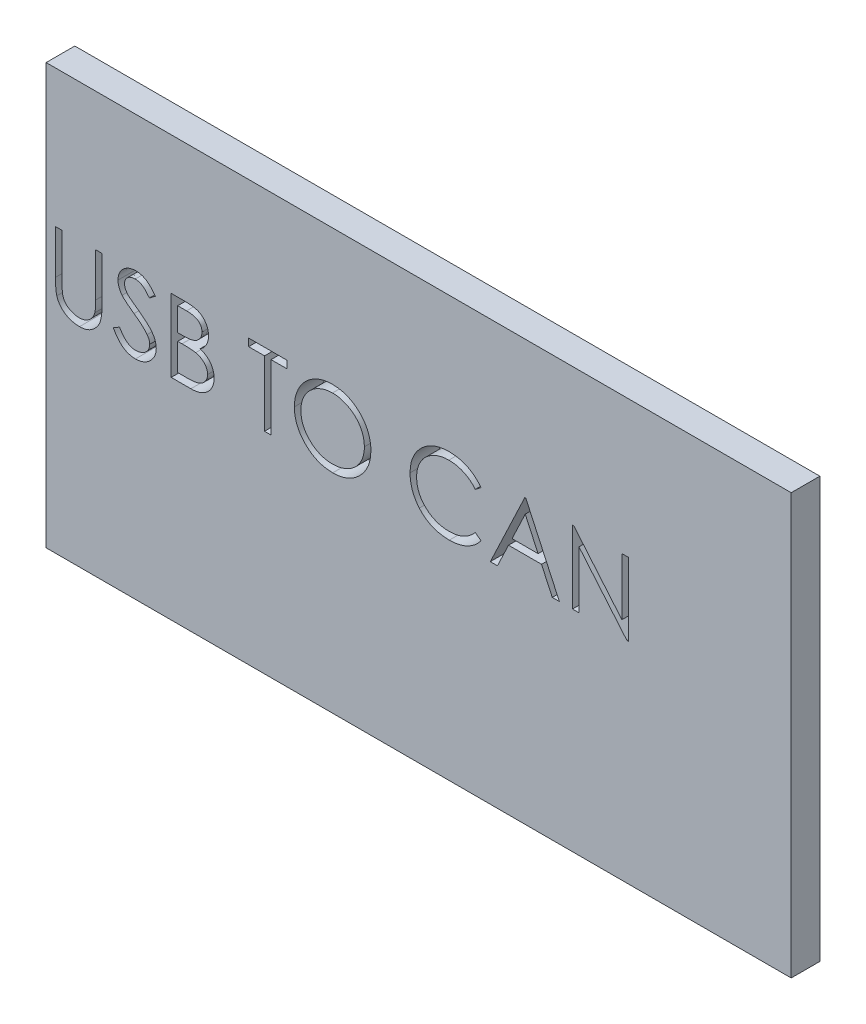
from build123d import *

# Parameters (mm, degrees)
SKETCH1_W               = 78
SKETCH1_H               = 44
BOSS_EXTRUDE1_DEPTH     = 3
CUT_EXTRUDE1_DEPTH      = 1
CUT_EXTRUDE1_DEPTH_BACK = 4


with BuildPart() as part:
    # Sketch1 → Boss-Extrude1 (new body)
    with BuildSketch(Plane.XY):
        Rectangle(SKETCH1_W, SKETCH1_H)
    extrude(amount=BOSS_EXTRUDE1_DEPTH)

    # Sketch2 → Cut-Extrude1 (cut, two sides)
    with BuildSketch(Plane.XY.offset(3)) as cut_extrude1_sk:
        with BuildLine():
            Line((-38.023076923, 7.62), (-37.339230769, 7.62))
            Line((-37.339230769, 7.62), (-37.339230769, 3.054411058))
            add(Edge.make_bspline(
                [(-37.339230769, 3.054411058), (-37.339332538, 2.989791856), (-37.33952566, 2.867165785), (-37.338235673, 2.692627942), (-37.334622991, 2.537457617), (-37.332345352, 2.401056683), (-37.327278415, 2.284051044), (-37.323146095, 2.185806796), (-37.317832655, 2.106789133), (-37.311446839, 2.060675231), (-37.308701923, 2.040853365)],
                knots=[0, 0, 0, 0, 0.000193858, 0.000367879, 0.000523606, 0.000659494, 0.000777119, 0.000874919, 0.000954528, 0.001014547, 0.001014547, 0.001014547, 0.001014547], degree=3))
            add(Edge.make_bspline(
                [(-37.308701923, 2.040853365), (-37.297429856, 1.969341269), (-37.275520861, 1.830346527), (-37.219685033, 1.632426211), (-37.141705217, 1.454049722), (-37.049300649, 1.289650854), (-36.927527364, 1.143805447), (-36.781651096, 1.009450363), (-36.604915497, 0.891946034), (-36.408405264, 0.784502267), (-36.196601404, 0.698145716), (-35.980168876, 0.632845877), (-35.762361018, 0.593050101), (-35.616544339, 0.588442093), (-35.544134615, 0.586153846)],
                knots=[0, 0, 0, 0, 0.000217082, 0.000421933, 0.000614749, 0.000800109, 0.000985589, 0.001182222, 0.00139307, 0.001620515, 0.001853241, 0.002077815, 0.002297904, 0.002515002, 0.002515002, 0.002515002, 0.002515002], degree=3))
            add(Edge.make_bspline(
                [(-35.544134615, 0.586153846), (-35.481969043, 0.588491772), (-35.357996952, 0.593154119), (-35.173796665, 0.622026149), (-34.994399857, 0.674061095), (-34.818920663, 0.741203655), (-34.654435377, 0.829916982), (-34.500852226, 0.932396924), (-34.363770746, 1.052598888), (-34.238676477, 1.185623067), (-34.129743273, 1.33571486), (-34.035318102, 1.49960612), (-33.957973078, 1.67976327), (-33.919778318, 1.806373755), (-33.90015625, 1.871418269)],
                knots=[0, 0, 0, 0, 0.000186532, 0.000371987, 0.000557549, 0.000746051, 0.000934521, 0.001116993, 0.001298788, 0.001480235, 0.001663726, 0.001853816, 0.002046631, 0.002250341, 0.002250341, 0.002250341, 0.002250341], degree=3))
            add(Edge.make_bspline(
                [(-33.90015625, 1.871418269), (-33.893624549, 1.89830288), (-33.879069286, 1.958212626), (-33.865468576, 2.059496122), (-33.851302941, 2.178998108), (-33.841474077, 2.317577198), (-33.831891992, 2.47476903), (-33.826159416, 2.651392482), (-33.823509761, 2.846806208), (-33.822720155, 2.983176257), (-33.822307692, 3.054411058)],
                knots=[0, 0, 0, 0, 8.2949e-05, 0.000184844, 0.000306213, 0.000444008, 0.000601498, 0.000778671, 0.000974079, 0.001187786, 0.001187786, 0.001187786, 0.001187786], degree=3))
            Line((-33.822307692, 3.054411058), (-33.822307692, 7.62))
            Line((-33.822307692, 7.62), (-33.138461538, 7.62))
            Line((-33.138461538, 7.62), (-33.138461538, 3.017776442))
            add(Edge.make_bspline(
                [(-33.138461538, 3.017776442), (-33.139014795, 2.934830829), (-33.140094508, 2.772957421), (-33.149457478, 2.535754748), (-33.164386146, 2.310740543), (-33.185478497, 2.097884559), (-33.213426487, 1.897948475), (-33.244505682, 1.709179808), (-33.284085122, 1.532933578), (-33.33031327, 1.367835572), (-33.383160252, 1.210677397), (-33.451612123, 1.061524356), (-33.52873632, 0.915842149), (-33.620208222, 0.775834209), (-33.722994146, 0.640880628), (-33.839366091, 0.511799841), (-33.965475264, 0.386529118), (-34.103418077, 0.268281814), (-34.250920649, 0.159841209), (-34.407544214, 0.064487204), (-34.572085638, -0.0161185), (-34.74411721, -0.082468941), (-34.923712343, -0.132357297), (-35.110875566, -0.169532351), (-35.306032896, -0.190655638), (-35.438761662, -0.193794926), (-35.505973558, -0.195384615)],
                knots=[0, 0, 0, 0, 0.000248829, 0.000485605, 0.000712033, 0.000925282, 0.001127125, 0.001317594, 0.001499055, 0.001668682, 0.001831847, 0.001995824, 0.002160411, 0.002325958, 0.002496927, 0.002668819, 0.002846917, 0.003029867, 0.003213358, 0.003395561, 0.003579198, 0.003762327, 0.003947888, 0.004137684, 0.004334233, 0.004535868, 0.004535868, 0.004535868, 0.004535868], degree=3))
            add(Edge.make_bspline(
                [(-35.505973558, -0.195384615), (-35.579276004, -0.193676069), (-35.723095141, -0.190323908), (-35.935014019, -0.171115521), (-36.138172355, -0.134934902), (-36.334715836, -0.088866682), (-36.521968621, -0.025329517), (-36.702439491, 0.048906972), (-36.873037534, 0.140079751), (-37.036530357, 0.241520223), (-37.188548826, 0.35565615), (-37.32809803, 0.480058471), (-37.455408354, 0.612734379), (-37.568333915, 0.755120318), (-37.66874567, 0.906108891), (-37.75524402, 1.066127236), (-37.829513426, 1.235113399), (-37.867845438, 1.352577224), (-37.887223558, 1.411959135)],
                knots=[0, 0, 0, 0, 0.00021994, 0.000431522, 0.000637552, 0.000838585, 0.001036493, 0.001230117, 0.001423349, 0.001616056, 0.001806861, 0.001992824, 0.002176366, 0.002357782, 0.002537286, 0.002719656, 0.002902855, 0.003090154, 0.003090154, 0.003090154, 0.003090154], degree=3))
            add(Edge.make_bspline(
                [(-37.887223558, 1.411959135), (-37.898494971, 1.452524911), (-37.922942916, 1.540512983), (-37.949123707, 1.686134424), (-37.971132622, 1.853806902), (-37.99182758, 2.043541894), (-38.004039083, 2.255486461), (-38.01474505, 2.489548729), (-38.023152345, 2.74601172), (-38.023102767, 2.924656122), (-38.023076923, 3.017776442)],
                knots=[0, 0, 0, 0, 0.000126253, 0.000273845, 0.000443307, 0.000633623, 0.000846243, 0.001080033, 0.001336589, 0.001615932, 0.001615932, 0.001615932, 0.001615932], degree=3))
            Line((-38.023076923, 3.017776442), (-38.023076923, 7.62))
        make_face()
        with BuildLine():
            Line((-31.966153846, 1.469963942), (-31.321995192, 1.856153846))
            add(Edge.make_bspline(
                [(-31.321995192, 1.856153846), (-31.262084059, 1.755865099), (-31.147296639, 1.563715731), (-30.955813965, 1.30407394), (-30.757404599, 1.083394045), (-30.55059925, 0.902959831), (-30.336660242, 0.760903683), (-30.11419096, 0.660314824), (-29.883941098, 0.597578329), (-29.727243806, 0.589958141), (-29.649014423, 0.586153846)],
                knots=[0, 0, 0, 0, 0.000350304, 0.00067117, 0.000966168, 0.001238859, 0.00149246, 0.001733624, 0.001968725, 0.002203113, 0.002203113, 0.002203113, 0.002203113], degree=3))
            add(Edge.make_bspline(
                [(-29.649014423, 0.586153846), (-29.582204744, 0.58801459), (-29.449754398, 0.59170352), (-29.2547646, 0.627149152), (-29.065392791, 0.68160413), (-28.885541985, 0.759591415), (-28.717693819, 0.853945489), (-28.570504385, 0.967910596), (-28.443258847, 1.095504678), (-28.339171575, 1.237852058), (-28.259313898, 1.390942535), (-28.197935738, 1.548079892), (-28.163874177, 1.711732604), (-28.158743188, 1.821918812), (-28.156153846, 1.877524038)],
                knots=[0, 0, 0, 0, 0.000200249, 0.000396995, 0.000592623, 0.000790249, 0.000983746, 0.001168767, 0.001346865, 0.001522724, 0.001695482, 0.001863598, 0.002027355, 0.002194185, 0.002194185, 0.002194185, 0.002194185], degree=3))
            add(Edge.make_bspline(
                [(-28.156153846, 1.877524038), (-28.159363631, 1.940967831), (-28.165888655, 2.069939791), (-28.221038906, 2.260221321), (-28.307796409, 2.448528002), (-28.387833936, 2.5650079), (-28.429387019, 2.625480769)],
                knots=[0, 0, 0, 0, 0.000190022, 0.000386287, 0.000589808, 0.000809558, 0.000809558, 0.000809558, 0.000809558], degree=3))
            add(Edge.make_bspline(
                [(-28.429387019, 2.625480769), (-28.463504185, 2.669125568), (-28.535128907, 2.760752364), (-28.658262691, 2.897139991), (-28.802751203, 3.03782352), (-28.9636498, 3.188174953), (-29.146819553, 3.341201527), (-29.346523456, 3.504200464), (-29.5678602, 3.67097304), (-29.72308939, 3.782818454), (-29.803185096, 3.840528846)],
                knots=[0, 0, 0, 0, 0.000166158, 0.000348828, 0.000550671, 0.000771029, 0.001009281, 0.001266508, 0.001544325, 0.00184049, 0.00184049, 0.00184049, 0.00184049], degree=3))
            add(Edge.make_bspline(
                [(-29.803185096, 3.840528846), (-29.883356196, 3.897632228), (-30.036637235, 4.006809547), (-30.250995634, 4.168841845), (-30.442681008, 4.31698307), (-30.610841381, 4.452627805), (-30.755402789, 4.575794447), (-30.877504387, 4.685300246), (-30.97403576, 4.784106741), (-31.027714481, 4.848204748), (-31.051814904, 4.876983173)],
                knots=[0, 0, 0, 0, 0.000295271, 0.000564536, 0.000806051, 0.001022036, 0.001212603, 0.001375761, 0.001513936, 0.001626521, 0.001626521, 0.001626521, 0.001626521], degree=3))
            add(Edge.make_bspline(
                [(-31.051814904, 4.876983173), (-31.085500845, 4.921834573), (-31.15174877, 5.010040871), (-31.239195902, 5.147908133), (-31.313521736, 5.289037642), (-31.371787156, 5.433808639), (-31.420851724, 5.580188684), (-31.453852705, 5.730087682), (-31.474516832, 5.882833017), (-31.476632985, 5.985623552), (-31.477692308, 6.037079327)],
                knots=[0, 0, 0, 0, 0.000168228, 0.000330842, 0.000489239, 0.000645995, 0.000798533, 0.000951847, 0.001105776, 0.001260067, 0.001260067, 0.001260067, 0.001260067], degree=3))
            add(Edge.make_bspline(
                [(-31.477692308, 6.037079327), (-31.474850681, 6.117698436), (-31.469228166, 6.277213478), (-31.42167824, 6.510234886), (-31.346625826, 6.732709314), (-31.241480956, 6.942434212), (-31.105937804, 7.133948719), (-30.949083426, 7.309455796), (-30.762259562, 7.456997681), (-30.55727585, 7.585910791), (-30.332907406, 7.686812491), (-30.097795782, 7.762927539), (-29.8515673, 7.806055123), (-29.684791332, 7.812244229), (-29.600168269, 7.815384615)],
                knots=[0, 0, 0, 0, 0.00024166, 0.000478156, 0.00071034, 0.000944489, 0.001179085, 0.001412476, 0.001648008, 0.001890713, 0.002137308, 0.002383992, 0.002630431, 0.00288428, 0.00288428, 0.00288428, 0.00288428], degree=3))
            add(Edge.make_bspline(
                [(-29.600168269, 7.815384615), (-29.510373971, 7.812287517), (-29.331801771, 7.806128378), (-29.069131193, 7.752576038), (-28.816232719, 7.663964861), (-28.612793382, 7.563405555), (-28.453572913, 7.462970872), (-28.332147707, 7.371487712), (-28.209101142, 7.26616819), (-28.083440691, 7.146731774), (-27.957295599, 7.012082562), (-27.828793111, 6.863142719), (-27.697632732, 6.700822446), (-27.613255688, 6.584945104), (-27.57, 6.525540865)],
                knots=[0, 0, 0, 0, 0.000269178, 0.000535309, 0.000800335, 0.001071346, 0.001214058, 0.001364566, 0.001526987, 0.001699738, 0.001884387, 0.002080254, 0.0022898, 0.002510221, 0.002510221, 0.002510221, 0.002510221], degree=3))
            Line((-27.57, 6.525540865), (-28.188209135, 6.056923077))
            add(Edge.make_bspline(
                [(-28.188209135, 6.056923077), (-28.225538279, 6.105013312), (-28.297425483, 6.197623859), (-28.406564538, 6.327319124), (-28.509431594, 6.445791573), (-28.610778464, 6.548694509), (-28.705252599, 6.641663154), (-28.796947417, 6.721258967), (-28.884543347, 6.788261835), (-28.994961307, 6.859766957), (-29.133683882, 6.930647116), (-29.307821644, 6.990625395), (-29.489800906, 7.02666813), (-29.613744846, 7.03143365), (-29.676490385, 7.033846154)],
                knots=[0, 0, 0, 0, 0.000182613, 0.000351669, 0.000508477, 0.000653127, 0.000784826, 0.000906023, 0.001017149, 0.001115377, 0.001300379, 0.001482851, 0.001666361, 0.00185451, 0.00185451, 0.00185451, 0.00185451], degree=3))
            add(Edge.make_bspline(
                [(-29.676490385, 7.033846154), (-29.755208299, 7.03120811), (-29.907008382, 7.026120891), (-30.122524267, 6.970560237), (-30.31649447, 6.883078587), (-30.48316034, 6.760472835), (-30.621924844, 6.615211702), (-30.722303015, 6.448053166), (-30.782719087, 6.263469764), (-30.790091502, 6.134709929), (-30.793846154, 6.069134615)],
                knots=[0, 0, 0, 0, 0.000235671, 0.000454469, 0.000662788, 0.000870407, 0.001071272, 0.001261588, 0.001450818, 0.001647207, 0.001647207, 0.001647207, 0.001647207], degree=3))
            add(Edge.make_bspline(
                [(-30.793846154, 6.069134615), (-30.792990261, 6.028309968), (-30.791277076, 5.946593916), (-30.767383373, 5.825868249), (-30.73668712, 5.705447562), (-30.688044019, 5.585873253), (-30.620889386, 5.465054105), (-30.532703832, 5.340909637), (-30.421640564, 5.212345631), (-30.336564326, 5.128727291), (-30.291646635, 5.084579327)],
                knots=[0, 0, 0, 0, 0.000122268, 0.000244736, 0.000368038, 0.000494742, 0.000630698, 0.000781885, 0.000950762, 0.001139653, 0.001139653, 0.001139653, 0.001139653], degree=3))
            add(Edge.make_bspline(
                [(-30.291646635, 5.084579327), (-30.274966732, 5.069694145), (-30.235339103, 5.03433036), (-30.162892659, 4.976435166), (-30.067222909, 4.905018845), (-29.95082806, 4.816654459), (-29.811561975, 4.71415139), (-29.649409342, 4.598820268), (-29.466177662, 4.466917069), (-29.336154519, 4.374698652), (-29.267403846, 4.3259375)],
                knots=[0, 0, 0, 0, 6.7059e-05, 0.000159318, 0.000278076, 0.000425226, 0.00059772, 0.000796814, 0.00102217, 0.00127503, 0.00127503, 0.00127503, 0.00127503], degree=3))
            add(Edge.make_bspline(
                [(-29.267403846, 4.3259375), (-29.184703086, 4.265758311), (-29.024564527, 4.149229654), (-28.796710024, 3.97415323), (-28.590112648, 3.802925803), (-28.404047045, 3.636640841), (-28.236675033, 3.476559678), (-28.089853481, 3.320756412), (-27.962086371, 3.17034725), (-27.824536187, 2.9775121), (-27.683984591, 2.740680139), (-27.563280509, 2.450514374), (-27.487171193, 2.159220671), (-27.477218351, 1.963437101), (-27.472307692, 1.866838942)],
                knots=[0, 0, 0, 0, 0.00030683, 0.000594134, 0.000861889, 0.001111615, 0.001342638, 0.001556449, 0.001753649, 0.001934112, 0.002266596, 0.002577286, 0.002874571, 0.0031641, 0.0031641, 0.0031641, 0.0031641], degree=3))
            add(Edge.make_bspline(
                [(-27.472307692, 1.866838942), (-27.473738376, 1.798523759), (-27.47657196, 1.663220027), (-27.509144007, 1.464544688), (-27.556866249, 1.271582623), (-27.628793027, 1.086719001), (-27.716582303, 0.906571832), (-27.827978534, 0.735866632), (-27.957099836, 0.570825273), (-28.105219062, 0.415848643), (-28.267298426, 0.273580639), (-28.43860407, 0.147025368), (-28.619416378, 0.041502904), (-28.808754474, -0.044604929), (-29.006661847, -0.111951616), (-29.213071936, -0.160747634), (-29.428324986, -0.190695782), (-29.574630035, -0.193804222), (-29.649014423, -0.195384615)],
                knots=[0, 0, 0, 0, 0.000204748, 0.00040552, 0.000602479, 0.000800075, 0.000999409, 0.001202649, 0.001410296, 0.001627314, 0.001844718, 0.002056602, 0.002265256, 0.002471552, 0.002679602, 0.002891382, 0.003107043, 0.003330092, 0.003330092, 0.003330092, 0.003330092], degree=3))
            add(Edge.make_bspline(
                [(-29.649014423, -0.195384615), (-29.706567941, -0.1942717), (-29.82095015, -0.192059885), (-29.990134794, -0.172506355), (-30.155901556, -0.144841175), (-30.316170365, -0.100919343), (-30.473006101, -0.047629467), (-30.625726652, 0.017985989), (-30.774406032, 0.096618296), (-30.919877455, 0.186523464), (-31.061770944, 0.291152039), (-31.198755614, 0.413014337), (-31.335326012, 0.548749408), (-31.467451143, 0.702043263), (-31.597803532, 0.870419318), (-31.723813098, 1.055452911), (-31.848088152, 1.256136178), (-31.926063542, 1.397356737), (-31.966153846, 1.469963942)],
                knots=[0, 0, 0, 0, 0.000172596, 0.000343018, 0.000510406, 0.000676283, 0.000840891, 0.001007049, 0.001174332, 0.001345035, 0.001519664, 0.001702462, 0.001894587, 0.002096914, 0.002309112, 0.002533088, 0.00276819, 0.003016977, 0.003016977, 0.003016977, 0.003016977], degree=3))
        make_face()
        with BuildLine():
            Line((-25.909230769, 7.62), (-24.422475962, 7.62))
            add(Edge.make_bspline(
                [(-24.422475962, 7.62), (-24.349697389, 7.619617366), (-24.208634403, 7.618875727), (-24.003505218, 7.607373596), (-23.81137495, 7.591690177), (-23.63218788, 7.566805233), (-23.466026808, 7.536778564), (-23.31239098, 7.500416324), (-23.171768948, 7.456815525), (-23.003883505, 7.387481621), (-22.812467666, 7.284452323), (-22.605207166, 7.132207847), (-22.427978507, 6.945991456), (-22.275172868, 6.735934932), (-22.153685859, 6.504862195), (-22.065796132, 6.258280761), (-22.010152986, 5.99937114), (-22.004430509, 5.821622278), (-22.001538462, 5.731790865)],
                knots=[0, 0, 0, 0, 0.000218303, 0.000423125, 0.000616188, 0.000796444, 0.000965604, 0.001122583, 0.001269827, 0.00140674, 0.001666957, 0.001920042, 0.002174807, 0.002434948, 0.002697141, 0.00295497, 0.003218413, 0.003487591, 0.003487591, 0.003487591, 0.003487591], degree=3))
            add(Edge.make_bspline(
                [(-22.001538462, 5.731790865), (-22.003918554, 5.64763873), (-22.008595661, 5.482271848), (-22.053320183, 5.240404101), (-22.123338552, 5.01016859), (-22.220668266, 4.792405569), (-22.347164612, 4.592035245), (-22.497079009, 4.407441254), (-22.677949076, 4.246439239), (-22.813461501, 4.156429834), (-22.882295673, 4.110709135)],
                knots=[0, 0, 0, 0, 0.000252237, 0.00049567, 0.000735161, 0.000972914, 0.001208822, 0.001444137, 0.001684104, 0.00193183, 0.00193183, 0.00193183, 0.00193183], degree=3))
            add(Edge.make_bspline(
                [(-22.882295673, 4.110709135), (-22.795731542, 4.077475051), (-22.630112916, 4.013890017), (-22.402196512, 3.901472235), (-22.205829449, 3.779199298), (-22.039501949, 3.645671098), (-21.89725254, 3.501742773), (-21.773040136, 3.345303924), (-21.66705383, 3.174313829), (-21.576238836, 2.990555275), (-21.505375544, 2.795904621), (-21.452305718, 2.592187674), (-21.421896586, 2.380134928), (-21.417569207, 2.235822188), (-21.415384615, 2.16296875)],
                knots=[0, 0, 0, 0, 0.000278068, 0.000532013, 0.000761127, 0.000970673, 0.001170357, 0.001367031, 0.001568637, 0.001772753, 0.001980893, 0.00218896, 0.00240332, 0.002621863, 0.002621863, 0.002621863, 0.002621863], degree=3))
            add(Edge.make_bspline(
                [(-21.415384615, 2.16296875), (-21.417511349, 2.088582588), (-21.421695756, 1.942225732), (-21.45256758, 1.727221696), (-21.504838836, 1.521753955), (-21.576839446, 1.324493528), (-21.670809971, 1.135822036), (-21.785170854, 0.95552573), (-21.921528715, 0.78541613), (-22.07406559, 0.623602985), (-22.246630604, 0.478109345), (-22.432810619, 0.348535149), (-22.634950321, 0.24197258), (-22.849729805, 0.152457127), (-23.079558402, 0.084079169), (-23.323404078, 0.036241737), (-23.58105653, 0.004009056), (-23.757861759, 0.001359027), (-23.848533654, 0)],
                knots=[0, 0, 0, 0, 0.000223117, 0.000438988, 0.000650013, 0.000858153, 0.001067726, 0.00128115, 0.001497372, 0.001720864, 0.001947195, 0.002173294, 0.002400016, 0.002631331, 0.002870379, 0.003117949, 0.003376203, 0.003648064, 0.003648064, 0.003648064, 0.003648064], degree=3))
            Line((-23.848533654, 0), (-25.909230769, 0))
            Line((-25.909230769, 0), (-25.909230769, 7.62))
        make_face()
        with BuildLine():
            Line((-25.225384615, 6.838461538), (-25.225384615, 4.396153846))
            Line((-25.225384615, 4.396153846), (-24.765925481, 4.396153846))
            add(Edge.make_bspline(
                [(-24.765925481, 4.396153846), (-24.698763246, 4.397024536), (-24.568992122, 4.398706885), (-24.381061376, 4.403526028), (-24.206617765, 4.417020054), (-24.045962403, 4.430510202), (-23.899348282, 4.452444018), (-23.767100218, 4.478552583), (-23.647142701, 4.506165079), (-23.508808033, 4.553124934), (-23.351894928, 4.622527186), (-23.184618285, 4.730234441), (-23.037150668, 4.858521176), (-22.912624219, 5.006547213), (-22.81070896, 5.169541594), (-22.739921958, 5.34490366), (-22.69192187, 5.528262919), (-22.687586022, 5.654141515), (-22.685384615, 5.718052885)],
                knots=[0, 0, 0, 0, 0.000201514, 0.000389365, 0.000563808, 0.000726329, 0.000872907, 0.001008219, 0.001130763, 0.001241785, 0.00144606, 0.001643798, 0.00183636, 0.002030242, 0.002222143, 0.002410366, 0.002595846, 0.002787146, 0.002787146, 0.002787146, 0.002787146], degree=3))
            add(Edge.make_bspline(
                [(-22.685384615, 5.718052885), (-22.686530185, 5.760345564), (-22.688777344, 5.843307274), (-22.707181392, 5.964246153), (-22.738461654, 6.077988266), (-22.778639286, 6.186092358), (-22.834784946, 6.285178157), (-22.900890543, 6.378671629), (-22.980760532, 6.46338887), (-23.071672167, 6.542570463), (-23.176193797, 6.612771407), (-23.294263067, 6.674255583), (-23.427477381, 6.723765502), (-23.573591654, 6.767125811), (-23.734854993, 6.797580325), (-23.909406449, 6.822951415), (-24.098675752, 6.835867842), (-24.229620232, 6.837577689), (-24.297307692, 6.838461538)],
                knots=[0, 0, 0, 0, 0.000126842, 0.000248814, 0.000365823, 0.000480347, 0.000593767, 0.000706445, 0.000823096, 0.000942139, 0.001067456, 0.001199905, 0.001340512, 0.001493156, 0.001656606, 0.001832326, 0.002022103, 0.002225172, 0.002225172, 0.002225172, 0.002225172], degree=3))
            Line((-24.297307692, 6.838461538), (-25.225384615, 6.838461538))
        make_face(mode=Mode.SUBTRACT)
        with BuildLine():
            Line((-25.225384615, 3.614615385), (-25.225384615, 0.781538462))
            Line((-25.225384615, 0.781538462), (-24.251514423, 0.781538462))
            add(Edge.make_bspline(
                [(-24.251514423, 0.781538462), (-24.181804647, 0.782373934), (-24.047448244, 0.783984198), (-23.853462138, 0.789241029), (-23.673666923, 0.801198497), (-23.508883039, 0.820021747), (-23.357331139, 0.840439971), (-23.220829283, 0.867896531), (-23.098270959, 0.899353982), (-22.956159466, 0.947978666), (-22.796131828, 1.02351784), (-22.623678478, 1.137413384), (-22.47035054, 1.273100128), (-22.340145947, 1.430139433), (-22.233437669, 1.600895636), (-22.15581065, 1.781914941), (-22.107933413, 1.970206289), (-22.10213749, 2.098585246), (-22.099230769, 2.16296875)],
                knots=[0, 0, 0, 0, 0.000209145, 0.000403099, 0.00058211, 0.000749497, 0.000900607, 0.001040708, 0.001166961, 0.001279917, 0.001490909, 0.001695816, 0.001898005, 0.002102827, 0.002305729, 0.002499948, 0.002691721, 0.002884658, 0.002884658, 0.002884658, 0.002884658], degree=3))
            add(Edge.make_bspline(
                [(-22.099230769, 2.16296875), (-22.099831888, 2.203231394), (-22.101024429, 2.283107243), (-22.119008968, 2.400489683), (-22.145164878, 2.51419287), (-22.178979029, 2.624525551), (-22.22822484, 2.729492959), (-22.285715661, 2.831171103), (-22.353123055, 2.929694392), (-22.458157496, 3.054253641), (-22.610931931, 3.197764395), (-22.828007825, 3.338271757), (-23.074835514, 3.451587269), (-23.253856513, 3.499700986), (-23.346334135, 3.524555288)],
                knots=[0, 0, 0, 0, 0.000120676, 0.000239405, 0.000355304, 0.00047068, 0.000584755, 0.000702331, 0.000820883, 0.000942252, 0.001190655, 0.001446369, 0.001714819, 0.002001676, 0.002001676, 0.002001676, 0.002001676], degree=3))
            add(Edge.make_bspline(
                [(-23.346334135, 3.524555288), (-23.383408909, 3.5320775), (-23.463794667, 3.548387206), (-23.594875171, 3.565603406), (-23.744522977, 3.580941507), (-23.913083641, 3.592286942), (-24.100770427, 3.604014217), (-24.307984175, 3.608574942), (-24.533878672, 3.614016188), (-24.690616351, 3.614410543), (-24.77203125, 3.614615385)],
                knots=[0, 0, 0, 0, 0.000113461, 0.000246007, 0.000396375, 0.000564727, 0.000752783, 0.000960469, 0.001186429, 0.001430665, 0.001430665, 0.001430665, 0.001430665], degree=3))
            Line((-24.77203125, 3.614615385), (-25.225384615, 3.614615385))
        make_face(mode=Mode.SUBTRACT)
        Polygon((-17.800769231, 6.838461538), (-17.800769231, 7.62), (-13.795384615, 7.62), (-13.795384615, 6.838461538), (-15.456153846, 6.838461538), (-15.456153846, 0), (-16.14, 0), (-16.14, 6.838461538), align=None)
        with BuildLine():
            add(Edge.make_bspline(
                [(-9.057307692, 7.815384615), (-8.916211187, 7.81181088), (-8.639086011, 7.80479177), (-8.231797233, 7.751061836), (-7.842970197, 7.658107872), (-7.469437495, 7.534309036), (-7.115667072, 7.369163203), (-6.778996112, 7.169551537), (-6.460225661, 6.93338279), (-6.163652253, 6.662482587), (-5.892256264, 6.367733468), (-5.65314962, 6.053184418), (-5.452760398, 5.720737311), (-5.288199341, 5.37139116), (-5.159097797, 5.005936029), (-5.070011193, 4.622423601), (-5.013104706, 4.22333875), (-5.006451842, 3.951137404), (-5.003076923, 3.813052885)],
                knots=[0, 0, 0, 0, 0.000423221, 0.000831241, 0.001229628, 0.001621103, 0.002009702, 0.002398454, 0.002793504, 0.003197651, 0.0036017, 0.003993999, 0.004380915, 0.004763982, 0.005150679, 0.005541287, 0.00594346, 0.006357532, 0.006357532, 0.006357532, 0.006357532], degree=3))
            add(Edge.make_bspline(
                [(-5.003076923, 3.813052885), (-5.006451348, 3.67598553), (-5.013102729, 3.405809895), (-5.070075896, 3.009257596), (-5.159428016, 2.628060137), (-5.287000459, 2.262853887), (-5.450777072, 1.913253591), (-5.652500616, 1.580179137), (-5.890116623, 1.263521332), (-6.160532682, 0.966749187), (-6.455320093, 0.694611836), (-6.771507131, 0.457479884), (-7.101982873, 0.253429076), (-7.451000009, 0.090614334), (-7.813929804, -0.039517675), (-8.194020462, -0.128241973), (-8.589490959, -0.185472621), (-8.85917583, -0.192044362), (-8.99625, -0.195384615)],
                knots=[0, 0, 0, 0, 0.000411021, 0.000810171, 0.001199294, 0.001584045, 0.001968493, 0.00235541, 0.002750148, 0.003154295, 0.003558344, 0.003951861, 0.004338265, 0.004721332, 0.00510515, 0.005492788, 0.005890425, 0.006301447, 0.006301447, 0.006301447, 0.006301447], degree=3))
            add(Edge.make_bspline(
                [(-8.99625, -0.195384615), (-9.134333803, -0.192011379), (-9.406533736, -0.185361832), (-9.806120082, -0.128361173), (-10.189901913, -0.039226106), (-10.556781729, 0.088157295), (-10.906964118, 0.252786809), (-11.241133955, 0.453528914), (-11.557949927, 0.69172389), (-11.854785387, 0.962052261), (-12.126382213, 1.25634004), (-12.363166911, 1.571664904), (-12.563954157, 1.901840498), (-12.728030898, 2.247783108), (-12.85792895, 2.607820363), (-12.946549154, 2.984353905), (-13.003886284, 3.375237058), (-13.010493578, 3.641377311), (-13.013846154, 3.776418269)],
                knots=[0, 0, 0, 0, 0.000414071, 0.000816245, 0.001208338, 0.001594531, 0.00197898, 0.002367203, 0.002761941, 0.003166089, 0.003570138, 0.003961517, 0.004347128, 0.004727436, 0.005108377, 0.005493046, 0.005886149, 0.006291071, 0.006291071, 0.006291071, 0.006291071], degree=3))
            add(Edge.make_bspline(
                [(-13.013846154, 3.776418269), (-13.012682176, 3.867058537), (-13.010368904, 4.047195606), (-12.982519562, 4.314693747), (-12.942108087, 4.577889979), (-12.884191923, 4.836035872), (-12.808445494, 5.088499501), (-12.719069366, 5.337022019), (-12.60990776, 5.579084869), (-12.486505892, 5.815834768), (-12.348775898, 6.043581123), (-12.196646409, 6.258856101), (-12.035460836, 6.463466157), (-11.858756533, 6.652109062), (-11.672357301, 6.830272623), (-11.473239346, 6.995218881), (-11.26261766, 7.148435203), (-11.039585965, 7.286510345), (-10.809639892, 7.411389376), (-10.572599593, 7.518552377), (-10.331684429, 7.610528088), (-10.085766024, 7.685075256), (-9.835497417, 7.74392786), (-9.580332389, 7.784003299), (-9.320474221, 7.811923671), (-9.145407292, 7.814226004), (-9.057307692, 7.815384615)],
                knots=[0, 0, 0, 0, 0.000271814, 0.000540199, 0.000805962, 0.001070372, 0.001333106, 0.001596279, 0.001862082, 0.002129039, 0.002396846, 0.002659828, 0.002919436, 0.003177585, 0.003434554, 0.003692536, 0.003952677, 0.004215283, 0.004478911, 0.004737128, 0.004995111, 0.005251998, 0.00550748, 0.005765706, 0.006026495, 0.00629068, 0.00629068, 0.00629068, 0.00629068], degree=3))
        make_face()
        with BuildLine():
            add(Edge.make_bspline(
                [(-9.023725962, 7.033846154), (-9.096038964, 7.03296465), (-9.239973651, 7.031210069), (-9.453953127, 7.00809814), (-9.665118423, 6.97515821), (-9.873513148, 6.928172157), (-10.078265356, 6.864155333), (-10.281283581, 6.790478841), (-10.480716516, 6.700734639), (-10.675905772, 6.599339208), (-10.865132307, 6.487109843), (-11.043685674, 6.363074168), (-11.212028116, 6.230140972), (-11.369747457, 6.088000023), (-11.51638058, 5.935927462), (-11.654813559, 5.776228729), (-11.779497619, 5.604339184), (-11.893766218, 5.424919955), (-11.996021916, 5.238204741), (-12.08695106, 5.04615927), (-12.161330987, 4.847216992), (-12.221991361, 4.643536226), (-12.272282949, 4.435439556), (-12.304143092, 4.221348365), (-12.327508972, 4.002338436), (-12.329163264, 3.854332228), (-12.33, 3.779471154)],
                knots=[0, 0, 0, 0, 0.000216841, 0.000431609, 0.000644918, 0.000857839, 0.001071742, 0.001288099, 0.00150539, 0.001727277, 0.001947698, 0.002164915, 0.002378992, 0.002590822, 0.002801321, 0.003012418, 0.003224302, 0.003437726, 0.003650187, 0.00386256, 0.004074625, 0.004286625, 0.00449989, 0.004716215, 0.00493554, 0.00516001, 0.00516001, 0.00516001, 0.00516001], degree=3))
            add(Edge.make_bspline(
                [(-12.33, 3.779471154), (-12.327224443, 3.669389976), (-12.321764065, 3.452826244), (-12.273959298, 3.135468171), (-12.200324028, 2.830475959), (-12.091777419, 2.539518431), (-11.956031223, 2.260094592), (-11.788332679, 1.994683233), (-11.589648613, 1.743212621), (-11.363958307, 1.507438349), (-11.117238585, 1.292236913), (-10.855257042, 1.103340577), (-10.580820331, 0.943515976), (-10.293212787, 0.81331179), (-9.993969859, 0.710137561), (-9.681163305, 0.639426941), (-9.356876876, 0.592889521), (-9.135830135, 0.588420378), (-9.023725962, 0.586153846)],
                knots=[0, 0, 0, 0, 0.000330065, 0.000649339, 0.000960692, 0.001269773, 0.001579024, 0.001891143, 0.002209643, 0.002538934, 0.002868918, 0.00319045, 0.003506453, 0.003820003, 0.004136183, 0.004454247, 0.004780867, 0.005116965, 0.005116965, 0.005116965, 0.005116965], degree=3))
            add(Edge.make_bspline(
                [(-9.023725962, 0.586153846), (-8.948376132, 0.587189087), (-8.79893479, 0.589242281), (-8.576658253, 0.609922257), (-8.358386158, 0.643084213), (-8.144424657, 0.690830383), (-7.935016582, 0.750586873), (-7.729287896, 0.821578555), (-7.529429904, 0.910147347), (-7.332921343, 1.008005458), (-7.144824383, 1.119562601), (-6.965263367, 1.239388516), (-6.798764233, 1.372125913), (-6.641162884, 1.512154979), (-6.493927743, 1.662299128), (-6.358054469, 1.822363154), (-6.234000582, 1.993357384), (-6.119775374, 2.172504468), (-6.017877985, 2.359730595), (-5.92909606, 2.552472351), (-5.853775374, 2.750255132), (-5.792971029, 2.953364211), (-5.745323253, 3.16141383), (-5.712492113, 3.37468256), (-5.689526655, 3.592743757), (-5.687795658, 3.740231809), (-5.686923077, 3.814579327)],
                knots=[0, 0, 0, 0, 0.000225996, 0.000448218, 0.000669067, 0.000887945, 0.001105376, 0.001322137, 0.00154021, 0.001760705, 0.001980349, 0.002195842, 0.002407776, 0.002618585, 0.002827992, 0.003038098, 0.003247849, 0.003461273, 0.003675073, 0.003886803, 0.004097441, 0.004309441, 0.004522362, 0.004737178, 0.004956503, 0.005179447, 0.005179447, 0.005179447, 0.005179447], degree=3))
            add(Edge.make_bspline(
                [(-5.686923077, 3.814579327), (-5.687796357, 3.888418225), (-5.689528669, 4.03489128), (-5.712481143, 4.251431691), (-5.745357938, 4.463165825), (-5.792738463, 4.669262448), (-5.853807655, 4.869774094), (-5.929109214, 5.064512442), (-6.017904637, 5.254202969), (-6.119812829, 5.438376839), (-6.234364993, 5.61510584), (-6.359538174, 5.784057378), (-6.497493589, 5.942058603), (-6.644289678, 6.093010137), (-6.803593148, 6.233692514), (-6.974682382, 6.364152402), (-7.155480332, 6.487538216), (-7.346910485, 6.598845868), (-7.544473036, 6.701637997), (-7.747195424, 6.78970561), (-7.952781064, 6.864538624), (-8.16070716, 6.928365845), (-8.372723816, 6.974974185), (-8.587398437, 7.008127825), (-8.804434017, 7.031202025), (-8.950396684, 7.032961981), (-9.023725962, 7.033846154)],
                knots=[0, 0, 0, 0, 0.000221418, 0.000439224, 0.000652533, 0.000863966, 0.001073044, 0.001280831, 0.001489792, 0.001700916, 0.00191177, 0.002121198, 0.002331138, 0.002540545, 0.002752495, 0.002968043, 0.003185656, 0.003408704, 0.003631946, 0.003853428, 0.004071217, 0.004288042, 0.00450543, 0.004721754, 0.00493956, 0.005159453, 0.005159453, 0.005159453, 0.005159453], degree=3))
        make_face(mode=Mode.SUBTRACT)
        with BuildLine():
            Line((6.524615385, 6.221778846), (5.92625, 5.763846154))
            add(Edge.make_bspline(
                [(5.92625, 5.763846154), (5.88356518, 5.814717208), (5.798771025, 5.915773465), (5.662352989, 6.057678644), (5.520181984, 6.190626442), (5.372312354, 6.315250191), (5.2160825, 6.427191836), (5.05527699, 6.532284923), (4.887205817, 6.626484969), (4.65479204, 6.740704385), (4.350758725, 6.859894585), (3.968028247, 6.959832477), (3.56849837, 7.023451151), (3.29592531, 7.030341463), (3.157283654, 7.033846154)],
                knots=[0, 0, 0, 0, 0.000199176, 0.000395666, 0.000590059, 0.000782959, 0.000975315, 0.001166267, 0.00135901, 0.001552886, 0.00194293, 0.002336139, 0.002737684, 0.00315335, 0.00315335, 0.00315335, 0.00315335], degree=3))
            add(Edge.make_bspline(
                [(3.157283654, 7.033846154), (3.080902299, 7.03296667), (2.928848481, 7.031215864), (2.703190947, 7.008118283), (2.481747105, 6.975654448), (2.264660998, 6.927484459), (2.052208957, 6.866584071), (1.84300207, 6.79381217), (1.640069279, 6.703776776), (1.440603286, 6.604263364), (1.249495404, 6.491863042), (1.0686727, 6.36926083), (0.898794667, 6.237828683), (0.739726922, 6.097073988), (0.591306852, 5.947630634), (0.454609907, 5.787905982), (0.330109099, 5.618410678), (0.215336605, 5.441379774), (0.11254774, 5.257328925), (0.026485545, 5.065576914), (-0.049725607, 4.86940741), (-0.110030815, 4.666604026), (-0.15776362, 4.458593775), (-0.190698704, 4.244818403), (-0.213533604, 4.025724506), (-0.215275704, 3.877223088), (-0.216153846, 3.802367788)],
                knots=[0, 0, 0, 0, 0.000229048, 0.00045597, 0.000679837, 0.000900206, 0.001122459, 0.001342606, 0.001564087, 0.001787996, 0.002011045, 0.002228658, 0.002442997, 0.002654947, 0.002865424, 0.003074369, 0.003285023, 0.003495877, 0.003707001, 0.003916708, 0.004125919, 0.004337919, 0.00455084, 0.004765657, 0.004986501, 0.005210971, 0.005210971, 0.005210971, 0.005210971], degree=3))
            add(Edge.make_bspline(
                [(-0.216153846, 3.802367788), (-0.213406686, 3.689741315), (-0.208013001, 3.468614173), (-0.160010628, 3.144719301), (-0.087065258, 2.834431434), (0.022261227, 2.539690177), (0.157067845, 2.256861123), (0.327408834, 1.990729677), (0.524693981, 1.737274185), (0.751714289, 1.502484682), (1.000792094, 1.288006228), (1.268031833, 1.099137819), (1.552767911, 0.94169799), (1.85185646, 0.810686357), (2.167599028, 0.709978853), (2.499427826, 0.639082104), (2.846621141, 0.592834843), (3.083863092, 0.588407213), (3.204603365, 0.586153846)],
                knots=[0, 0, 0, 0, 0.000337689, 0.000663007, 0.000980291, 0.001292238, 0.001604234, 0.001918459, 0.00223816, 0.002566349, 0.002896488, 0.003222997, 0.003546206, 0.003870912, 0.004201103, 0.00453853, 0.004887849, 0.005249876, 0.005249876, 0.005249876, 0.005249876], degree=3))
            add(Edge.make_bspline(
                [(3.204603365, 0.586153846), (3.337632648, 0.589830561), (3.5994661, 0.597067215), (3.983444489, 0.658373923), (4.35102407, 0.757777733), (4.702224616, 0.896892638), (5.036056046, 1.077737636), (5.353040775, 1.296971301), (5.653446365, 1.556679042), (5.8340867, 1.754980025), (5.92625, 1.856153846)],
                knots=[0, 0, 0, 0, 0.000398895, 0.000785121, 0.001163193, 0.001539336, 0.001915653, 0.002299692, 0.002693579, 0.003103877, 0.003103877, 0.003103877, 0.003103877], degree=3))
            Line((5.92625, 1.856153846), (6.524615385, 1.402800481))
            add(Edge.make_bspline(
                [(6.524615385, 1.402800481), (6.4764611, 1.340668194), (6.380383186, 1.216701231), (6.224808875, 1.041938251), (6.060919444, 0.87755518), (5.887497584, 0.72487733), (5.706538278, 0.580849608), (5.514792272, 0.449563906), (5.314780265, 0.329187753), (5.107179942, 0.218965706), (4.892211876, 0.121174442), (4.670133649, 0.037455096), (4.441902511, -0.03466252), (4.207508027, -0.09399388), (3.966464008, -0.140304068), (3.71964029, -0.171262332), (3.466504161, -0.192471871), (3.295725982, -0.194404991), (3.209182692, -0.195384615)],
                knots=[0, 0, 0, 0, 0.00023577, 0.00047041, 0.000701393, 0.000931724, 0.001163205, 0.001394807, 0.001628318, 0.001863212, 0.002099574, 0.002336295, 0.002574782, 0.002817275, 0.003061263, 0.003310615, 0.003563259, 0.003822826, 0.003822826, 0.003822826, 0.003822826], degree=3))
            add(Edge.make_bspline(
                [(3.209182692, -0.195384615), (3.127227051, -0.19481422), (2.96516992, -0.193686334), (2.725904638, -0.175415387), (2.492973037, -0.150487674), (2.267040851, -0.112953446), (2.046875157, -0.068660911), (1.834471827, -0.00928749), (1.627740769, 0.05722241), (1.427512553, 0.135392696), (1.233616864, 0.223602213), (1.04667908, 0.323296978), (0.866785179, 0.433638638), (0.69216652, 0.552194975), (0.525402638, 0.682774129), (0.365048391, 0.823562631), (0.2102046, 0.974085957), (0.114404469, 1.082627095), (0.066237981, 1.137199519)],
                knots=[0, 0, 0, 0, 0.0002458, 0.000486039, 0.000719505, 0.000948369, 0.001172896, 0.001392858, 0.001609596, 0.00182418, 0.002037297, 0.002248306, 0.002459308, 0.002670156, 0.002881148, 0.003094244, 0.003310126, 0.003528424, 0.003528424, 0.003528424, 0.003528424], degree=3))
            add(Edge.make_bspline(
                [(0.066237981, 1.137199519), (-0.010910477, 1.231994908), (-0.16427599, 1.420441231), (-0.360492478, 1.725863854), (-0.528453727, 2.044746068), (-0.664255017, 2.37876317), (-0.770418453, 2.727165653), (-0.843964941, 3.090129145), (-0.89175672, 3.467314665), (-0.897221977, 3.723862187), (-0.9, 3.854266827)],
                knots=[0, 0, 0, 0, 0.000366426, 0.000728427, 0.001086882, 0.001446309, 0.001808466, 0.002177883, 0.00255617, 0.002947238, 0.002947238, 0.002947238, 0.002947238], degree=3))
            add(Edge.make_bspline(
                [(-0.9, 3.854266827), (-0.896614121, 3.991329843), (-0.889952617, 4.26099277), (-0.833356056, 4.656740634), (-0.742310563, 5.035893108), (-0.612995051, 5.397742404), (-0.449044544, 5.744191757), (-0.246512316, 6.072594608), (-0.00775128, 6.385051183), (0.265365996, 6.676820442), (0.564869737, 6.943606118), (0.88560384, 7.178315625), (1.226940536, 7.373643474), (1.585119402, 7.536920833), (1.962822514, 7.662421064), (2.359244021, 7.750275717), (2.77363903, 7.804959267), (3.056368082, 7.811872148), (3.200024038, 7.815384615)],
                knots=[0, 0, 0, 0, 0.000411021, 0.000808659, 0.001196655, 0.001579034, 0.001959341, 0.002344444, 0.002734312, 0.003137157, 0.003541534, 0.003936009, 0.004327172, 0.004719298, 0.005115115, 0.005518766, 0.005935868, 0.006366714, 0.006366714, 0.006366714, 0.006366714], degree=3))
            add(Edge.make_bspline(
                [(3.200024038, 7.815384615), (3.287576689, 7.814334932), (3.460878343, 7.812257188), (3.717242689, 7.791996388), (3.966835412, 7.758221051), (4.209828465, 7.71224835), (4.447403989, 7.655191267), (4.677746228, 7.580862961), (4.902206797, 7.495874855), (5.119370066, 7.397993852), (5.328194098, 7.288120547), (5.528613854, 7.167472818), (5.719037347, 7.036200236), (5.900804497, 6.895419265), (6.070874648, 6.742151545), (6.234076495, 6.580612779), (6.384867757, 6.406149996), (6.47794757, 6.283348397), (6.524615385, 6.221778846)],
                knots=[0, 0, 0, 0, 0.000262619, 0.000519828, 0.000770894, 0.001017881, 0.001261486, 0.001503344, 0.001743462, 0.001981214, 0.002217458, 0.002450969, 0.002682571, 0.002910967, 0.003140157, 0.003368981, 0.003599453, 0.003831196, 0.003831196, 0.003831196, 0.003831196], degree=3))
        make_face()
        Polygon((11.213846154, 7.62), (14.730769231, 0), (13.987391827, 0), (12.860877404, 2.442307692), (9.406538462, 2.442307692), (8.24796875, 0), (7.501538462, 0), (11.116153846, 7.62), align=None)
        Polygon((11.157367788, 6.134771635), (9.777463942, 3.223846154), (12.500637019, 3.223846154), align=None, mode=Mode.SUBTRACT)
        Polygon((16.098461538, 0), (16.098461538, 7.62), (16.241947115, 7.62), (21.276153846, 1.622608173), (21.276153846, 7.62), (21.96, 7.62), (21.96, 0), (21.804302885, 0), (16.782307692, 5.983653846), (16.782307692, 0), align=None)
    extrude(amount=CUT_EXTRUDE1_DEPTH, mode=Mode.SUBTRACT)
    extrude(cut_extrude1_sk.sketch, amount=-CUT_EXTRUDE1_DEPTH_BACK, mode=Mode.SUBTRACT)


solid = part.part
